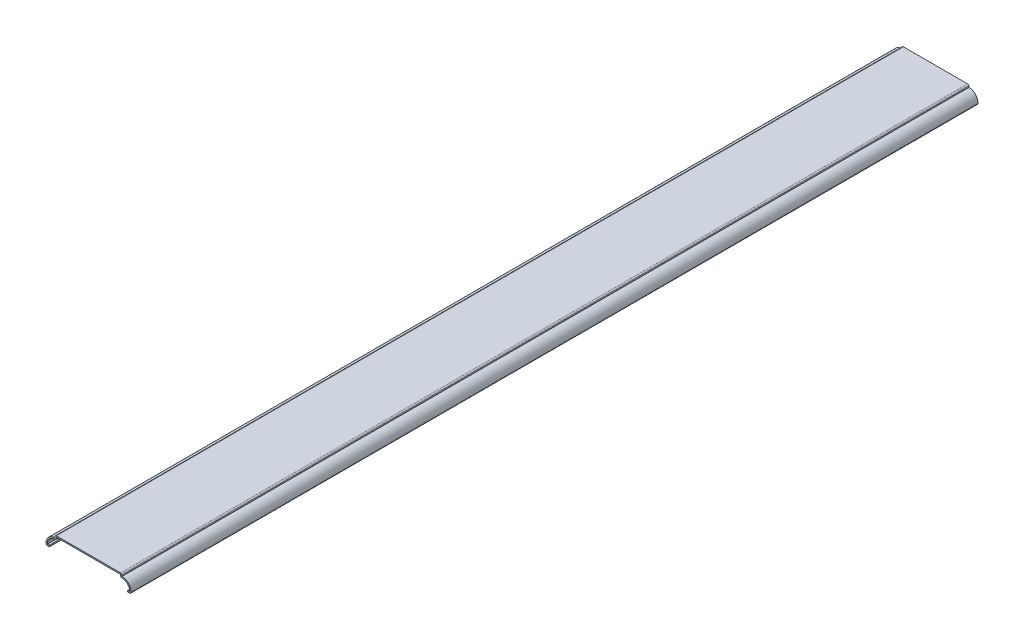
from build123d import *

# Parameters (mm, degrees)
EXTRUDE_THIN1_DEPTH = 825.5
FILLET1_R           = 1.27


with BuildPart() as part:
    # Sketch1 → Extrude-Thin1 (new body)
    with BuildSketch(Plane.XY):
        with BuildLine():
            Line((-38.1, 0), (-41.275, 0))
            ThreePointArc((-41.275, 0), (-39.354822583, 7.228599878), (-32.54375, 10.31875))
            Line((-32.54375, 10.31875), (-32.54375, 12.7))
            Line((-32.54375, 12.7), (32.54375, 12.7))
            Line((32.54375, 12.7), (32.54375, 10.31875))
            ThreePointArc((32.54375, 10.31875), (39.354822583, 7.228599878), (41.275, 0))
            Line((41.275, 0), (38.1, 0))
            Line((38.1, 0), (38.1, 1.27))
            Line((38.1, 1.27), (40.143945779, 1.27))
            ThreePointArc((40.143945779, 1.27), (37.560409803, 7.240667538), (31.27375, 8.914417078))
            Line((31.27375, 8.914417078), (31.27375, 11.43))
            Line((31.27375, 11.43), (-31.27375, 11.43))
            Line((-31.27375, 11.43), (-31.27375, 8.914417078))
            ThreePointArc((-31.27375, 8.914417078), (-37.560409803, 7.240667538), (-40.143945779, 1.27))
            Line((-40.143945779, 1.27), (-38.1, 1.27))
            Line((-38.1, 1.27), (-38.1, 0))
        make_face()
    extrude(amount=-EXTRUDE_THIN1_DEPTH)

    # Fillet1
    fillet1_edges = [part.edges().sort_by_distance(p)[0] for p in [
        (-41.275, 0, -412.75),
        (-32.54375, 12.7, -412.75),
        (32.54375, 12.7, -412.75),
        (41.275, 0, -412.75),
        (31.27375, 8.914417078, -412.75),
        (-31.27375, 8.914417078, -412.75),
    ]]
    fillet(fillet1_edges, radius=FILLET1_R)


solid = part.part
